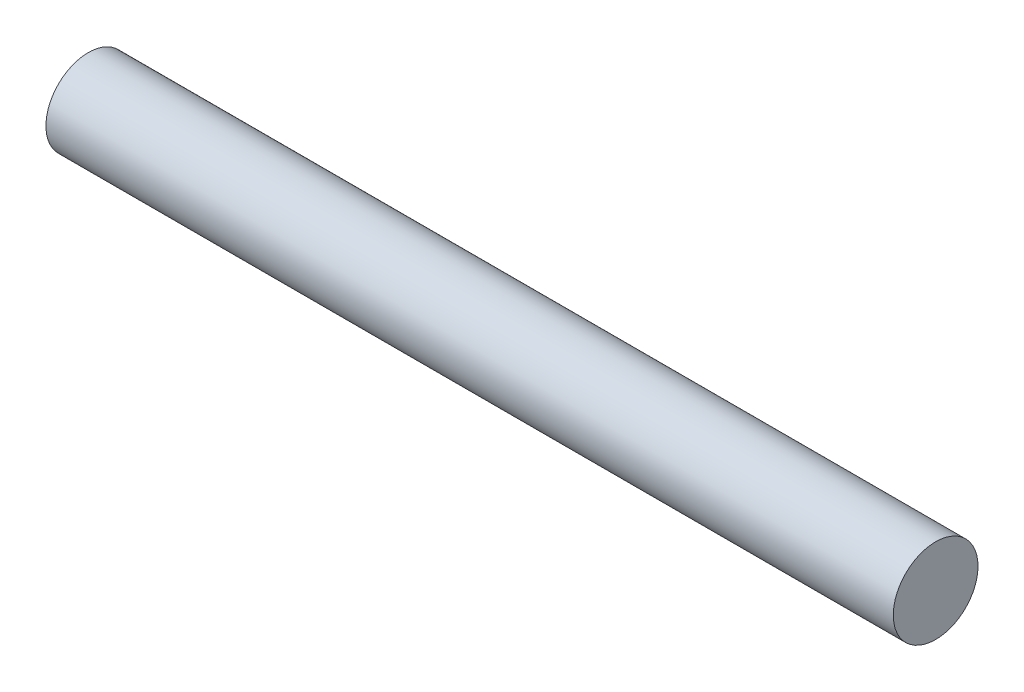
from build123d import *

# Parameters (mm, degrees)
SKETCH1_R           = 9.525
BOSS_EXTRUDE1_DEPTH = 190.5


with BuildPart() as part:
    # Sketch1 → Boss-Extrude1 (new body)
    with BuildSketch(Plane(origin=(0, 0, 0), x_dir=(0, 0, -1), z_dir=(1, 0, 0))):
        Circle(SKETCH1_R)
    extrude(amount=BOSS_EXTRUDE1_DEPTH)


solid = part.part
